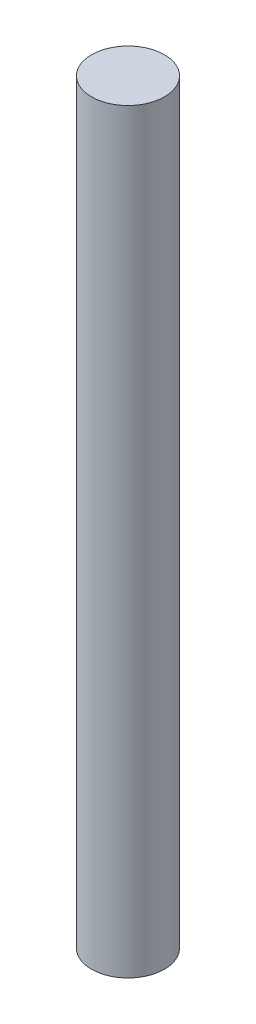
from build123d import *

# Parameters (mm, degrees)
SKETCH_1_R      = 7
EXTRUDE_1_DEPTH = 145


with BuildPart() as part:
    # 草图1 → 凸台-拉伸1 (new body)
    with BuildSketch(Plane(origin=(0, 0, 0), x_dir=(1, 0, 0), z_dir=(0, 1, 0))):
        Circle(SKETCH_1_R)
    extrude(amount=EXTRUDE_1_DEPTH)


solid = part.part
